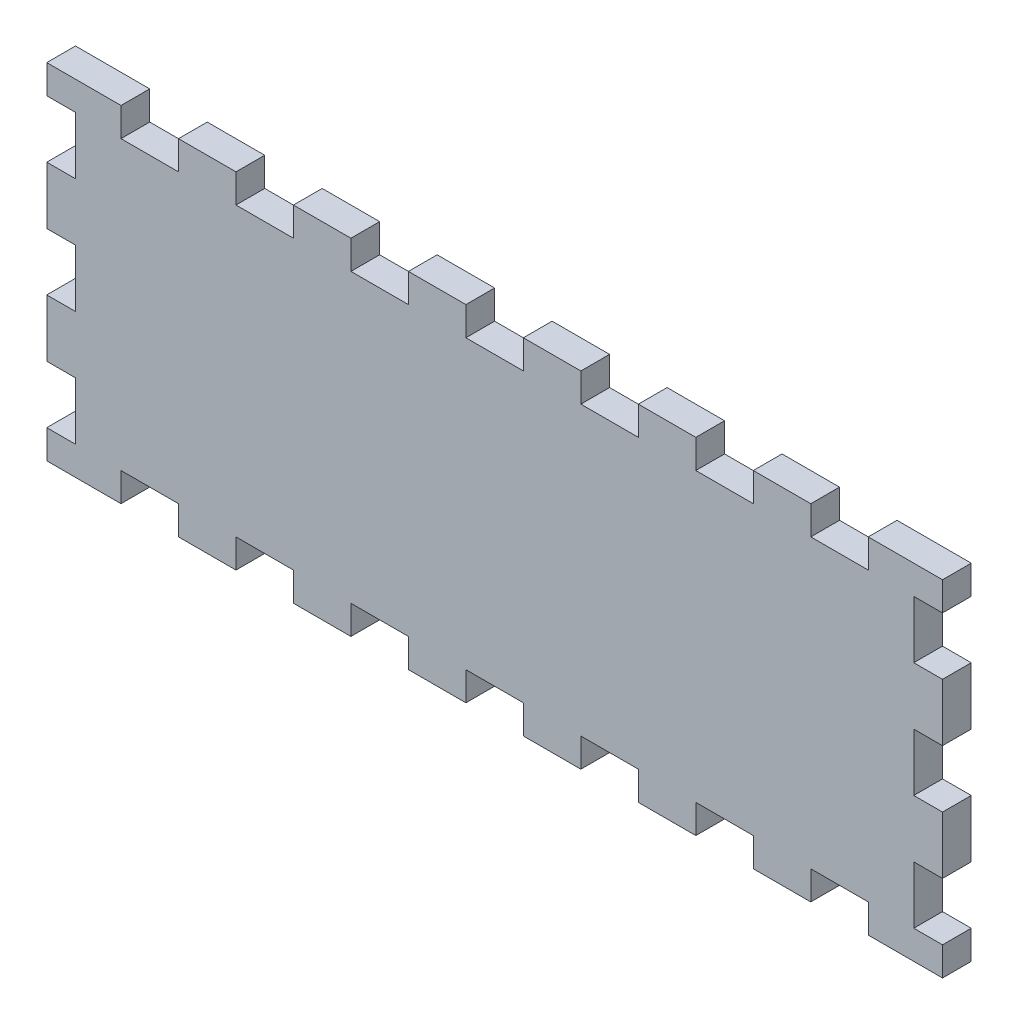
from build123d import *

# Parameters (mm, degrees)
BOSS_EXTRUDE1_DEPTH = 6


with BuildPart() as part:
    # Sketch1 → Boss-Extrude1 (new body)
    with BuildSketch(Plane.XY):
        Polygon((-93.5, 6), (-78, 6), (-78, 0), (-66, 0), (-66, 6), (-54, 6), (-54, 0), (-42, 0), (-42, 6), (-30, 6), (-30, 0), (-18, 0), (-18, 6), (-6, 6), (-6, 0), (6, 0), (6, 6), (18, 6), (18, 0), (30, 0), (30, 6), (42, 6), (42, 0), (54, 0), (54, 6), (66, 6), (66, 0), (78, 0), (78, 6), (93.5, 6), (93.5, 0), (87.5, 0), (87.5, -12), (93.5, -12), (93.5, -24), (87.5, -24), (87.5, -36), (93.5, -36), (93.5, -48), (87.5, -48), (87.5, -60), (93.5, -60), (93.5, -66), (78, -66), (78, -60), (66, -60), (66, -66), (54, -66), (54, -60), (42, -60), (42, -66), (30, -66), (30, -60), (18, -60), (18, -66), (6, -66), (6, -60), (-6, -60), (-6, -66), (-18, -66), (-18, -60), (-30, -60), (-30, -66), (-42, -66), (-42, -60), (-54, -60), (-54, -66), (-66, -66), (-66, -60), (-78, -60), (-78, -66), (-93.5, -66), (-93.5, -60), (-87.5, -60), (-87.5, -48), (-93.5, -48), (-93.5, -36), (-87.5, -36), (-87.5, -24), (-93.5, -24), (-93.5, -12), (-87.5, -12), (-87.5, 0), (-93.5, 0), align=None)
    extrude(amount=BOSS_EXTRUDE1_DEPTH)


solid = part.part
